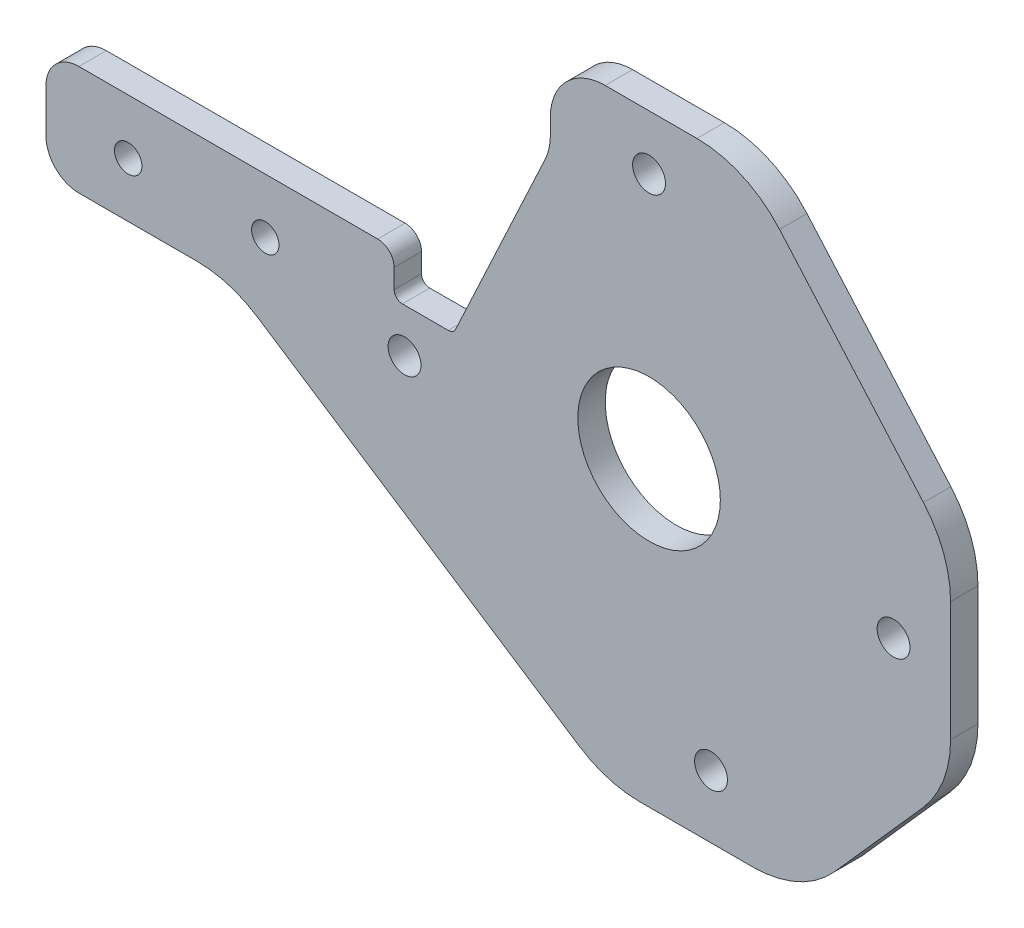
from build123d import *

# Parameters (mm, degrees)
SKETCH1_R                       = 3
SKETCH1_R_2                     = 13
SKETCH1_R_3                     = 2.5
BOSS_EXTRUDE1_DEPTH             = 2.5
CUT_EXTRUDE1_DEPTH              = 3.5
CUT_EXTRUDE1_DEPTH_BACK         = 3.5
BOSS_EXTRUDE2_REACH             = 4.5
BOSS_EXTRUDE2_DIRECTION_2_REACH = 4.5
FILLET2_R                       = 20
FILLET4_R                       = 6
FILLET5_R                       = 10
FILLET6_R                       = 3
FILLET7_R                       = 1.5


with BuildPart() as part:
    # Sketch1 → Boss-Extrude1 (new body, symmetric)
    with BuildSketch(Plane.XY):
        Polygon((-55, 10), (-110, 10), (-110, -10), (-55, -10), (-55, -55), (55, -55), (55, 55), (-55, 55), align=None)
        with Locations((0, 45)):
            Circle(SKETCH1_R, mode=Mode.SUBTRACT)
        with Locations((-44.598206242, -6)):
            Circle(SKETCH1_R, mode=Mode.SUBTRACT)
        with Locations((44.598206242, -6)):
            Circle(SKETCH1_R, mode=Mode.SUBTRACT)
        with Locations((11.3, -43.55812209)):
            Circle(SKETCH1_R, mode=Mode.SUBTRACT)
        Circle(SKETCH1_R_2, mode=Mode.SUBTRACT)
        with Locations((-95, 0)):
            Circle(SKETCH1_R_3, mode=Mode.SUBTRACT)
        with Locations((-70, 0)):
            Circle(SKETCH1_R_3, mode=Mode.SUBTRACT)
    extrude(amount=BOSS_EXTRUDE1_DEPTH, both=True)

    # Sketch2 → Cut-Extrude1 (cut, two sides)
    with BuildSketch(Plane.XY) as cut_extrude1_sk:
        Polygon((17.823700244, 55), (55, 12.487274774), (55, 55), align=None)
        Polygon((55, -24.415324997), (27.884298804, -55), (55, -55), align=None)
        Polygon((-7.739125069, -55), (-55, -24.068320295), (-55, -55), align=None)
        Polygon((-55, 55), (-18, 55), (-18, 39.905543875), (-35.675645396, 2), (-46.5, 2), (-46.5, 10), (-55, 10), align=None)
    extrude(amount=CUT_EXTRUDE1_DEPTH, mode=Mode.SUBTRACT)
    extrude(cut_extrude1_sk.sketch, amount=-CUT_EXTRUDE1_DEPTH_BACK, mode=Mode.SUBTRACT)

    # Boss-Extrude2: up to this face of the body (flat: up to its plane)
    boss_extrude2_end = Plane(part.part.faces().sort_by_distance((-48.483053202, 6, 2.5))[0])
    # Sketch3 → Boss-Extrude2 (add, up to the picked face)
    with BuildSketch(Plane.XY, mode=Mode.PRIVATE) as boss_extrude2_sk1:
        Polygon((-55, -24.068320295), (-76.495151, -10), (-55, -10), align=None)
    boss_extrude2_tool1 = split(extrude(boss_extrude2_sk1.sketch, amount=BOSS_EXTRUDE2_REACH, mode=Mode.PRIVATE), bisect_by=boss_extrude2_end, keep=Keep.BOTH, mode=Mode.PRIVATE)
    add(boss_extrude2_tool1.solids().sort_by_distance((-62.16505, -14.68944, 0))[0])

    # Boss-Extrude2 direction 2: up to this face of the body (flat: up to its plane)
    boss_extrude2_direction_2_end = Plane(part.part.faces().sort_by_distance((-78.25, 8.016946798, -2.5))[0])
    # Sketch3 → Boss-Extrude2 direction 2 (add, up to the picked face)
    with BuildSketch(Plane.XY, mode=Mode.PRIVATE) as boss_extrude2_direction_2_sk1:
        Polygon((-55, -24.068320295), (-76.495151, -10), (-55, -10), align=None)
    boss_extrude2_direction_2_tool1 = split(extrude(boss_extrude2_direction_2_sk1.sketch, amount=-BOSS_EXTRUDE2_DIRECTION_2_REACH, mode=Mode.PRIVATE), bisect_by=boss_extrude2_direction_2_end, keep=Keep.BOTH, mode=Mode.PRIVATE)
    add(boss_extrude2_direction_2_tool1.solids().sort_by_distance((-62.16505, -14.68944, 0))[0])

    # Fillet2
    fillet2_edges = [part.edges().sort_by_distance(p)[0] for p in [
        (-76.495151, -10, 0),
        (-7.739125069, -55, 0),
        (55, -24.415324997, 0),
        (27.884298804, -55, 0),
        (17.823700244, 55, 0),
        (55, 12.487274774, 0),
    ]]
    fillet(fillet2_edges, radius=FILLET2_R)

    # Fillet4
    fillet4_edges = [part.edges().sort_by_distance(p)[0] for p in [
        (-110, -10, 0),
        (-110, 10, 0),
    ]]
    fillet(fillet4_edges, radius=FILLET4_R)

    # Fillet5
    fillet5_edges = [part.edges().sort_by_distance(p)[0] for p in [
        (-18, 55, 0),
        (-18, 39.905543875, 0),
    ]]
    fillet(fillet5_edges, radius=FILLET5_R)

    # Fillet6
    fillet6_edges = [part.edges().sort_by_distance(p)[0] for p in [
        (-46.5, 10, 0),
    ]]
    fillet(fillet6_edges, radius=FILLET6_R)

    # Fillet7
    fillet7_edges = [part.edges().sort_by_distance(p)[0] for p in [
        (-35.675645396, 2, 0),
        (-46.5, 2, 0),
    ]]
    fillet(fillet7_edges, radius=FILLET7_R)


solid = part.part
